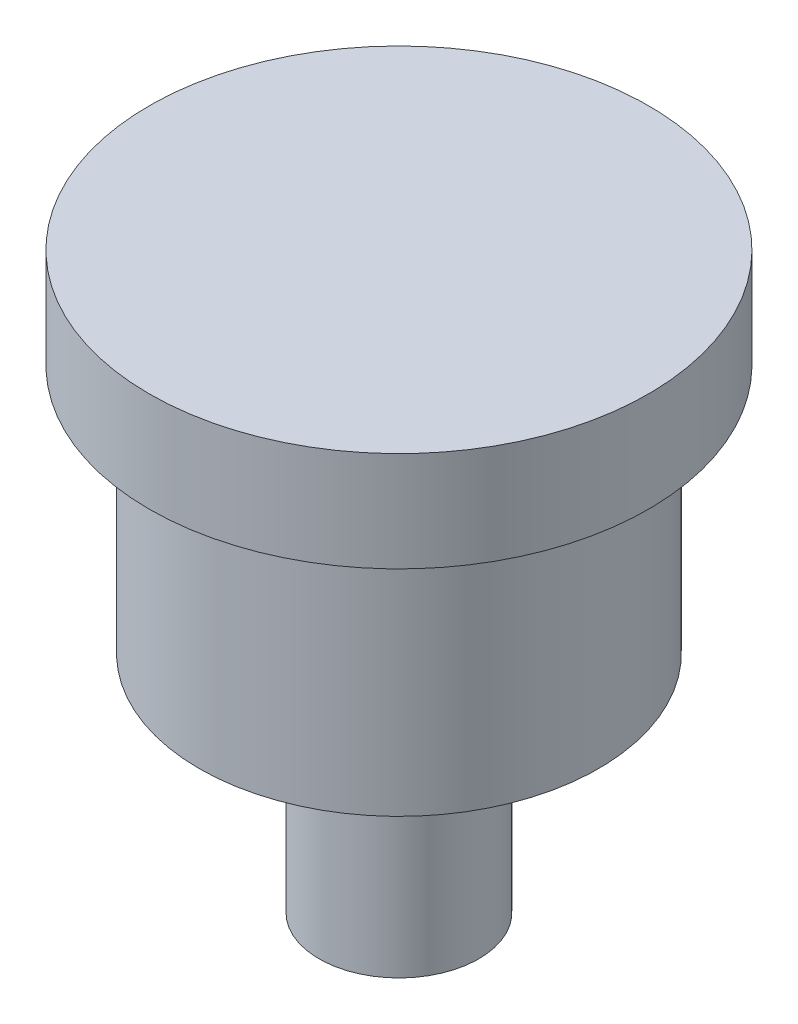
from build123d import *

# Parameters (mm, degrees)
SKETCH1_R           = 5
BOSS_EXTRUDE1_DEPTH = 2
SKETCH6_R           = 4
BOSS_EXTRUDE4_DEPTH = 5
SKETCH4_R           = 1.6
BOSS_EXTRUDE5_DEPTH = 4.5


with BuildPart() as part:
    # Sketch1 → Boss-Extrude1 (new body)
    with BuildSketch(Plane(origin=(0, 0, 0), x_dir=(1, 0, 0), z_dir=(0, 1, 0))):
        Circle(SKETCH1_R)
    extrude(amount=BOSS_EXTRUDE1_DEPTH)

    # Sketch6 → Boss-Extrude4 (add)
    with BuildSketch(Plane(origin=(0, 0, 0), x_dir=(-1, 0, 0), z_dir=(0, -1, 0))):
        Circle(SKETCH6_R)
    extrude(amount=BOSS_EXTRUDE4_DEPTH)

    # Sketch4 → Boss-Extrude5 (add)
    with BuildSketch(Plane(origin=(0, -5, 0), x_dir=(-1, 0, 0), z_dir=(0, -1, 0))):
        Circle(SKETCH4_R)
    extrude(amount=BOSS_EXTRUDE5_DEPTH)


solid = part.part
